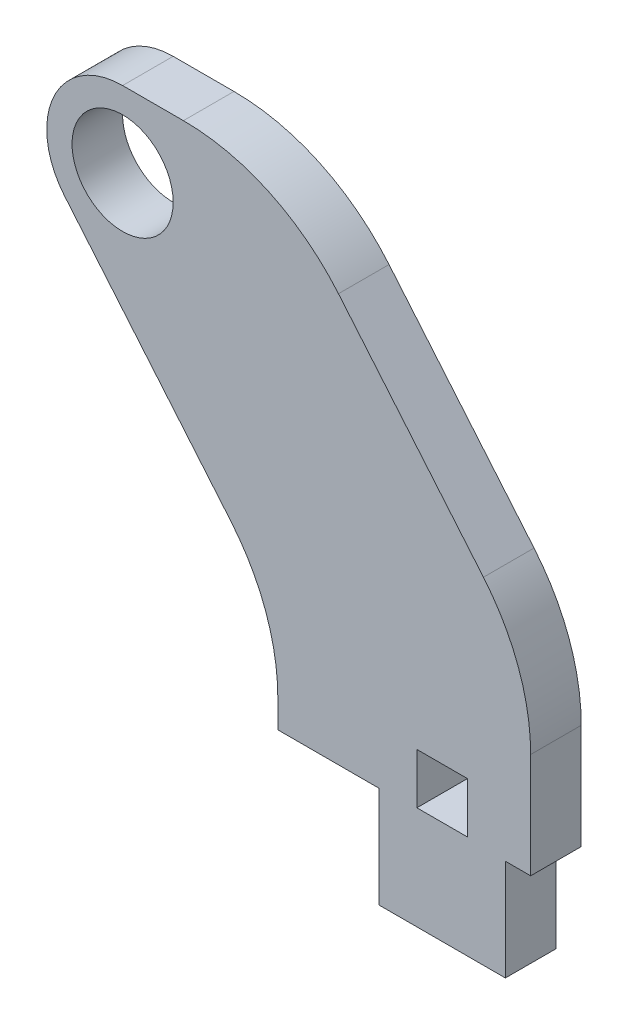
from build123d import *

# Parameters (mm, degrees)
SKETCH1_R           = 3.175
BOSS_EXTRUDE1_DEPTH = 3.175
CUT_EXTRUDE1_REACH  = 5.175
SKETCH2_W           = 3.175
SKETCH2_H           = 3.175
FILLET1_R           = 12.7


with BuildPart() as part:
    # Sketch1 → Boss-Extrude1 (new body)
    with BuildSketch(Plane.XY):
        with BuildLine():
            Line((-3.96875, 0), (3.96875, 0))
            Line((3.96875, 0), (3.96875, 6.35))
            Line((3.96875, 6.35), (5.55625, 6.35))
            Line((5.55625, 6.35), (5.55625, 17.564325962))
            Line((5.55625, 17.564325962), (-10.31875, 36.5125))
            Line((-10.31875, 36.5125), (-20.066, 36.5125))
            ThreePointArc((-20.066, 36.5125), (-24.38152939, 33.764351592), (-23.716600944, 28.691484184))
            Line((-23.716600944, 28.691484184), (-10.31875, 12.7))
            Line((-10.31875, 12.7), (-10.31875, 6.35))
            Line((-10.31875, 6.35), (-3.96875, 6.35))
            Line((-3.96875, 6.35), (-3.96875, 0))
        make_face()
        with Locations((-20.066, 31.75)):
            Circle(SKETCH1_R, mode=Mode.SUBTRACT)
    extrude(amount=BOSS_EXTRUDE1_DEPTH)

    # Sketch2 → Cut-Extrude1 (cut, up to next)
    with BuildSketch(Plane.XY.offset(3.175), mode=Mode.PRIVATE) as cut_extrude1_sk1:
        with Locations((0, 8.0645)):
            Rectangle(SKETCH2_W, SKETCH2_H)
    cut_extrude1_tool1 = extrude(cut_extrude1_sk1.sketch, amount=-CUT_EXTRUDE1_REACH, mode=Mode.PRIVATE) & part.part
    add(cut_extrude1_tool1.solids().sort_by_distance((0, 8.0645, 3.175))[0], mode=Mode.SUBTRACT)

    # Fillet1
    fillet1_edges = [part.edges().sort_by_distance(p)[0] for p in [
        (-10.31875, 12.7, 1.5875),
        (-10.31875, 36.5125, 1.5875),
        (5.55625, 17.564325962, 1.5875),
    ]]
    fillet(fillet1_edges, radius=FILLET1_R)


solid = part.part
